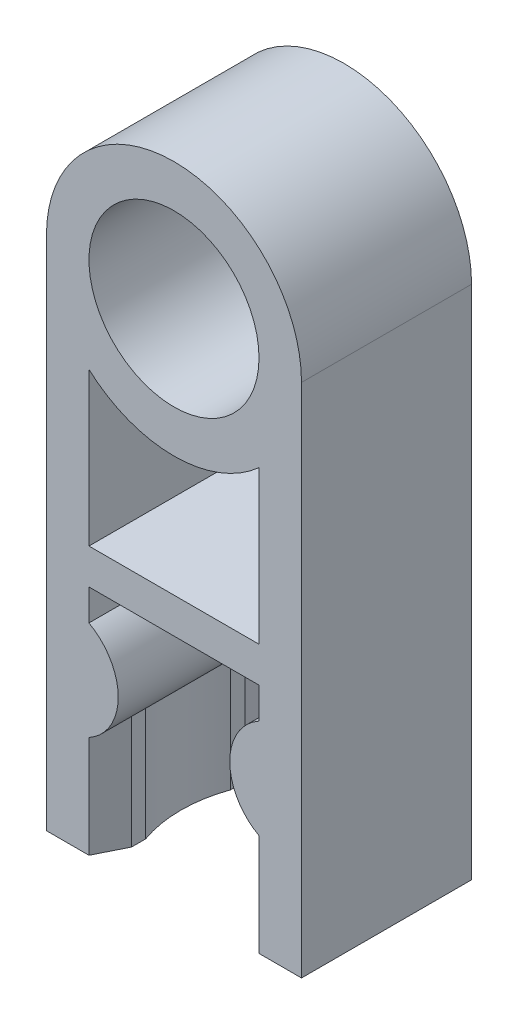
from build123d import *

# Parameters (mm, degrees)
EXTRUDE_1_DEPTH     = 6
SKETCH_2_R          = 3
CUT_EXTRUDE_1_DEPTH = 7
EXTRUDE_2_REACH     = 24.7


with BuildPart() as part:
    # 草图1 → 凸台-拉伸1 (new body)
    with BuildSketch(Plane.XY):
        with BuildLine():
            Line((-4.5, 0), (-4.5, -18.2))
            Line((-4.5, -18.2), (-3, -18.2))
            Line((-3, -18.2), (-3, -14.6))
            ThreePointArc((-3, -14.6), (-1.968245837, -12.85), (-3, -11.1))
            Line((-3, -11.1), (-3, -10))
            Line((-3, -10), (3, -10))
            Line((3, -10), (3, -11.1))
            ThreePointArc((3, -11.1), (1.968245837, -12.85), (3, -14.6))
            Line((3, -14.6), (3, -18.2))
            Line((3, -18.2), (4.5, -18.2))
            Line((4.5, -18.2), (4.5, 0))
            ThreePointArc((4.5, 0), (0, 4.5), (-4.5, 0))
        make_face()
    extrude(amount=EXTRUDE_1_DEPTH)

    # 草图2 → 切除-拉伸1 (cut, through all)
    with BuildSketch(Plane.XY):
        Circle(SKETCH_2_R)
        with BuildLine():
            Line((-3, -8.75), (-3, -3.354101966))
            ThreePointArc((-3, -3.354101966), (0, -4.5), (3, -3.354101966))
            Line((3, -3.354101966), (3, -8.75))
            Line((3, -8.75), (-3, -8.75))
        make_face()
    extrude(amount=CUT_EXTRUDE_1_DEPTH, mode=Mode.SUBTRACT)

    # 草图3 → 凸台-拉伸2 (add, up to next)
    with BuildSketch(Plane.XZ.offset(18.2), mode=Mode.PRIVATE) as extrude_2_sk1:
        with BuildLine():
            Line((-3, 6), (-3, 0))
            Line((-3, 0), (-2.5, 1))
            Line((-2.5, 1), (-2.5, 1.5))
            ThreePointArc((-2.5, 1.5), (-2.757359313, 3), (-2.5, 4.5))
            Line((-2.5, 4.5), (-2.5, 5))
            Line((-2.5, 5), (-3, 6))
        make_face()
    extrude_2_tool1 = extrude(extrude_2_sk1.sketch, amount=-EXTRUDE_2_REACH, mode=Mode.PRIVATE) - part.part
    add(extrude_2_tool1.solids().sort_by_distance((-2.809362, -18.2, 3))[0])
    # 草图3 → 凸台-拉伸2 (add, up to next)
    with BuildSketch(Plane.XZ.offset(18.2), mode=Mode.PRIVATE) as extrude_2_sk2:
        with BuildLine():
            Line((3, 0), (2.5, 1))
            Line((2.5, 1), (2.5, 1.5))
            ThreePointArc((2.5, 1.5), (2.757359313, 3), (2.5, 4.5))
            Line((2.5, 4.5), (2.5, 5))
            Line((2.5, 5), (3, 6))
            Line((3, 6), (3, 0))
        make_face()
    extrude_2_tool2 = extrude(extrude_2_sk2.sketch, amount=-EXTRUDE_2_REACH, mode=Mode.PRIVATE) - part.part
    add(extrude_2_tool2.solids().sort_by_distance((2.809362, -18.2, 3))[0])


solid = part.part
